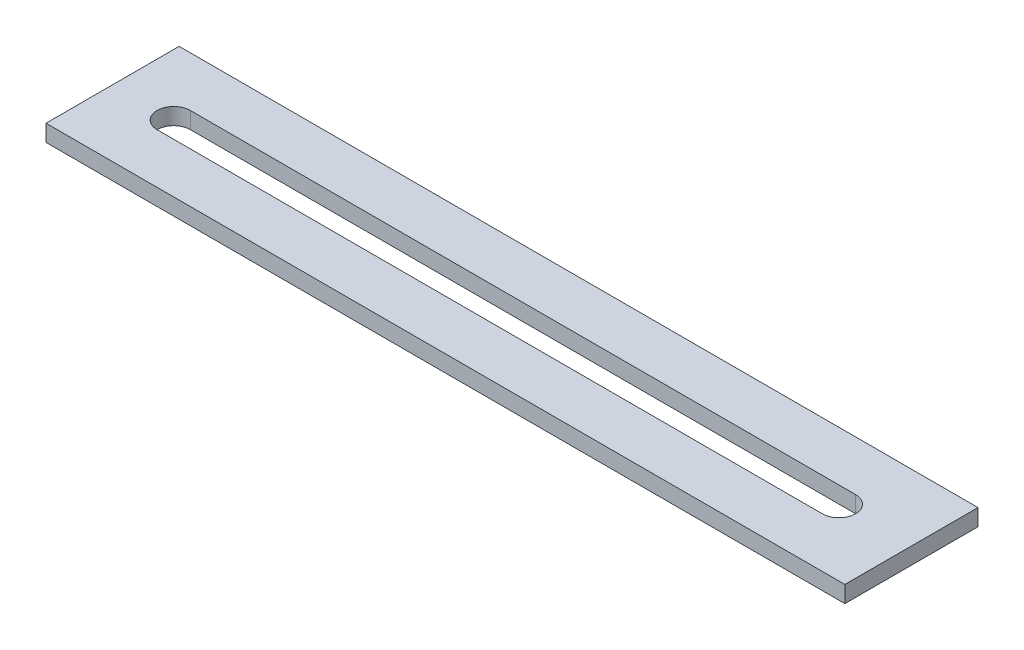
from build123d import *

# Parameters (mm, degrees)
SKETCH1_W           = 152.4
SKETCH1_H           = 25.4
BOSS_EXTRUDE1_DEPTH = 3.175


with BuildPart() as part:
    # Sketch1 → Boss-Extrude1 (new body)
    with BuildSketch(Plane(origin=(0, 0, 0), x_dir=(1, 0, 0), z_dir=(0, 1, 0))):
        with Locations((76.2, 12.7)):
            Rectangle(SKETCH1_W, SKETCH1_H)
        with BuildLine():
            Line((11.663316062, 15.875), (138.576758834, 15.875))
            ThreePointArc((138.576758834, 15.875), (141.751758834, 12.7), (138.576758834, 9.525))
            Line((138.576758834, 9.525), (11.663316062, 9.525))
            ThreePointArc((11.663316062, 9.525), (8.488316062, 12.7), (11.663316062, 15.875))
        make_face(mode=Mode.SUBTRACT)
    extrude(amount=BOSS_EXTRUDE1_DEPTH)


solid = part.part
